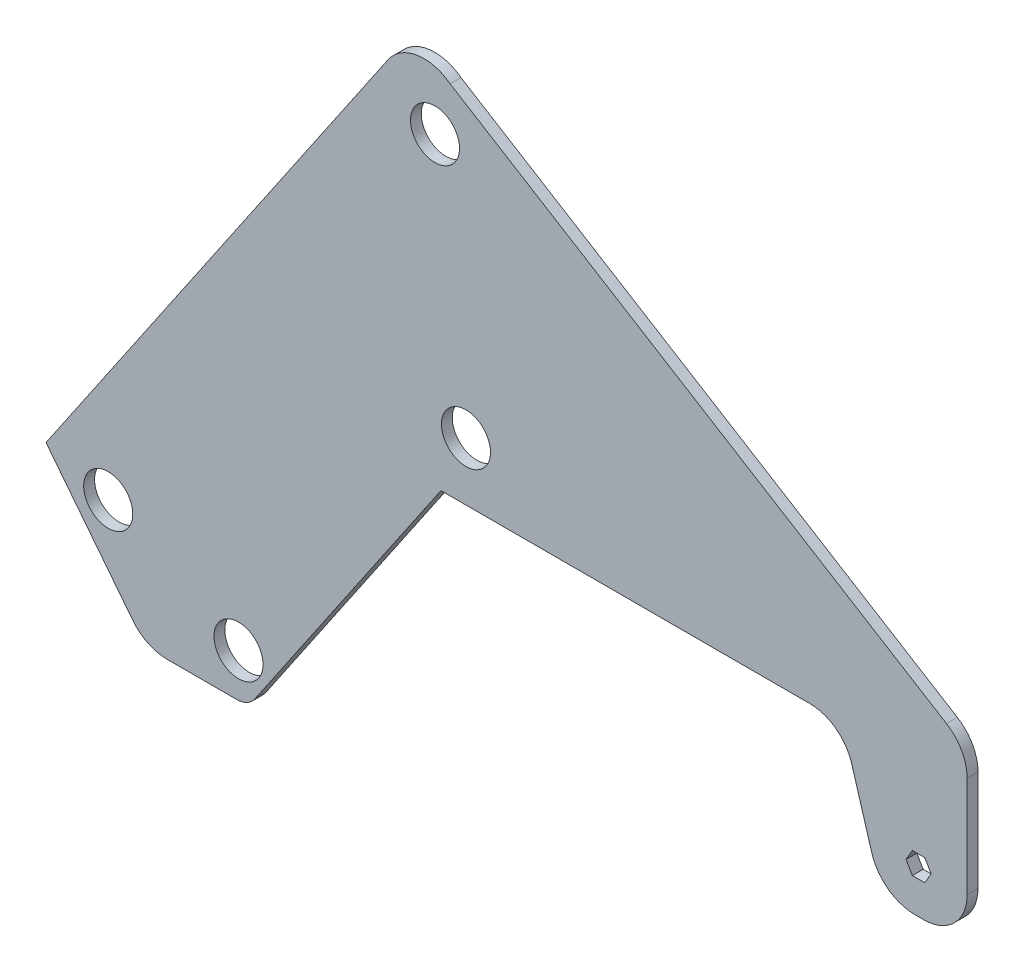
from build123d import *

# Parameters (mm, degrees)
MODEL_R             = 14.351
BOSS_EXTRUDE1_DEPTH = 6.35


with BuildPart() as part:
    # Model → Boss-Extrude1 (new body)
    with BuildSketch(Plane.XY):
        with BuildLine():
            Line((-314.23831963, -55.359484793), (-205.338802982, 104.650248016))
            Line((-205.338802982, 104.650248016), (-11.396613492, 104.650248016))
            Line((-11.396613492, 104.650248016), (-2.138802982, 104.650248016))
            Line((-2.138802982, 104.650248016), (10.561197018, 104.650248016))
            ThreePointArc((10.561197018, 104.650248016), (25.72621731, 99.626267243), (34.892121825, 86.541756641))
            Line((34.892121825, 86.541756641), (46.592108535, 47.500248016))
            ThreePointArc((46.592108535, 47.500248016), (56.051698972, 33.745564192), (71.88314884, 28.450248016))
            Line((71.88314884, 28.450248016), (77.072108535, 28.450248016))
            ThreePointArc((77.072108535, 28.450248016), (95.032620777, 35.889735774), (102.472108535, 53.850248016))
            Line((102.472108535, 53.850248016), (102.472108535, 83.872407327))
            Line((102.472108535, 83.872407327), (102.472108535, 112.853785651))
            ThreePointArc((102.472108535, 112.853785651), (99.24880288, 125.237413065), (90.396972478, 134.478031323))
            Line((90.396972478, 134.478031323), (-199.949582693, 313.389629113))
            ThreePointArc((-199.949582693, 313.389629113), (-219.402189514, 318.224062751), (-236.303247901, 307.447705012))
            Line((-236.303247901, 307.447705012), (-436.377385414, 13.472026599))
            Line((-436.377385414, 13.472026599), (-385.58146606, -51.20282143))
            ThreePointArc((-385.58146606, -51.20282143), (-376.71145599, -58.357541068), (-365.605974805, -60.913979882))
            Line((-365.605974805, -60.913979882), (-324.737451002, -60.913979882))
            ThreePointArc((-324.737451002, -60.913979882), (-318.798508014, -59.439796386), (-314.23831963, -55.359484793))
        make_face()
        with Locations((-323.775189267, -35.513979882)):
            Circle(MODEL_R, mode=Mode.SUBTRACT)
        with Locations((-399.975189267, 2.586020118)):
            Circle(MODEL_R, mode=Mode.SUBTRACT)
        Polygon((77.727371227, 60.200248016), (81.393545437, 53.850248016), (77.727371227, 47.500248016), (70.395022809, 47.500248016), (66.728848599, 53.850248016), (70.395022809, 60.200248016), align=None, mode=Mode.SUBTRACT)
        with Locations((-190.707148919, 138.516914683)):
            Circle(MODEL_R, mode=Mode.SUBTRACT)
        with Locations((-208.832932893, 283.437784316)):
            Circle(MODEL_R, mode=Mode.SUBTRACT)
    extrude(amount=BOSS_EXTRUDE1_DEPTH)


solid = part.part
